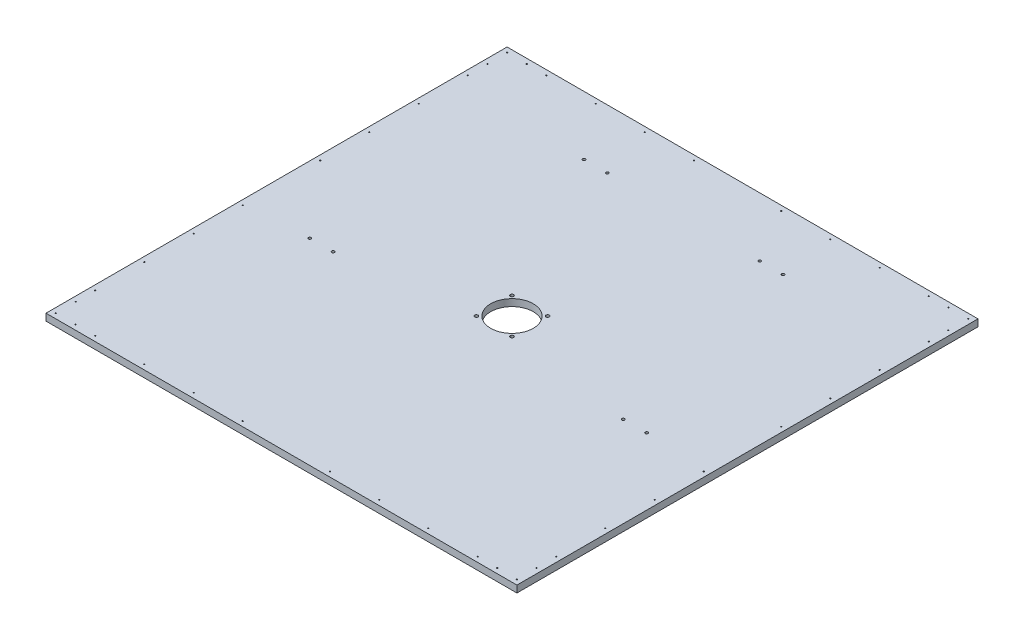
from build123d import *

# Parameters (mm, degrees)
SKETCH1_W               = 1216.025
SKETCH1_H               = 1190.625
BOSS_EXTRUDE1_DEPTH     = 17.8562
SKETCH3_R               = 55
CUT_EXTRUDE1_DEPTH      = 1
CUT_EXTRUDE1_DEPTH_BACK = 18.8562
SKETCH4_R               = 4.25
CUT_EXTRUDE2_DEPTH      = 1
CUT_EXTRUDE2_DEPTH_BACK = 18.8562
SKETCH5_R               = 1.3890625
CUT_EXTRUDE3_DEPTH      = 1
CUT_EXTRUDE3_DEPTH_BACK = 18.8562
SKETCH10_R              = 3.571875
CUT_EXTRUDE4_DEPTH      = 1
CUT_EXTRUDE4_DEPTH_BACK = 18.8562


with BuildPart() as part:
    # Sketch1 → Boss-Extrude1 (new body)
    with BuildSketch(Plane(origin=(0, 0, 0), x_dir=(1, 0, 0), z_dir=(0, 1, 0))):
        with Locations((608.0125, -595.3125)):
            Rectangle(SKETCH1_W, SKETCH1_H)
    extrude(amount=BOSS_EXTRUDE1_DEPTH)

    # Sketch3 → Cut-Extrude1 (cut, two sides)
    with BuildSketch(Plane(origin=(0, 17.8562, 0), x_dir=(1, 0, 0), z_dir=(0, 1, 0))) as cut_extrude1_sk:
        with Locations((608.0125, -595.376)):
            Circle(SKETCH3_R)
    extrude(amount=CUT_EXTRUDE1_DEPTH, mode=Mode.SUBTRACT)
    extrude(cut_extrude1_sk.sketch, amount=-CUT_EXTRUDE1_DEPTH_BACK, mode=Mode.SUBTRACT)

    # Sketch4 → Cut-Extrude2 (cut, two sides)
    with BuildSketch(Plane(origin=(0, 17.8562, 0), x_dir=(1, 0, 0), z_dir=(0, 1, 0))) as cut_extrude2_sk:
        with Locations((562.050559223, -549.414059223)):
            Circle(SKETCH4_R)
        with Locations((653.974440777, -549.414059223)):
            Circle(SKETCH4_R)
        with Locations((653.974440777, -641.337940777)):
            Circle(SKETCH4_R)
        with Locations((562.050559223, -641.337940777)):
            Circle(SKETCH4_R)
    extrude(amount=CUT_EXTRUDE2_DEPTH, mode=Mode.SUBTRACT)
    extrude(cut_extrude2_sk.sketch, amount=-CUT_EXTRUDE2_DEPTH_BACK, mode=Mode.SUBTRACT)

    # Sketch5 → Cut-Extrude3 (cut, two sides)
    with BuildSketch(Plane(origin=(0, 17.8562, 0), x_dir=(1, 0, 0), z_dir=(0, 1, 0))) as cut_extrude3_sk:
        with Locations((12.7, -12.7)):
            Circle(SKETCH5_R)
        with Locations((12.7, -63.5)):
            Circle(SKETCH5_R)
        with Locations((63.5, -12.7)):
            Circle(SKETCH5_R)
        with Locations((12.7, -114.3)):
            Circle(SKETCH5_R)
        with Locations((114.3, -12.7)):
            Circle(SKETCH5_R)
        with Locations((12.7, -241.3)):
            Circle(SKETCH5_R)
        with Locations((12.7, -368.3)):
            Circle(SKETCH5_R)
        with Locations((12.7, -495.3)):
            Circle(SKETCH5_R)
        with Locations((241.3, -12.7)):
            Circle(SKETCH5_R)
        with Locations((368.3, -12.7)):
            Circle(SKETCH5_R)
        with Locations((495.3, -12.7)):
            Circle(SKETCH5_R)
        with Locations((720.725, -12.7)):
            Circle(SKETCH5_R)
        with Locations((847.725, -12.7)):
            Circle(SKETCH5_R)
        with Locations((974.725, -12.7)):
            Circle(SKETCH5_R)
        with Locations((1203.325, -495.3)):
            Circle(SKETCH5_R)
        with Locations((1203.325, -368.3)):
            Circle(SKETCH5_R)
        with Locations((1203.325, -241.3)):
            Circle(SKETCH5_R)
        with Locations((1101.725, -12.7)):
            Circle(SKETCH5_R)
        with Locations((1203.325, -114.3)):
            Circle(SKETCH5_R)
        with Locations((1152.525, -12.7)):
            Circle(SKETCH5_R)
        with Locations((1203.325, -63.5)):
            Circle(SKETCH5_R)
        with Locations((1203.325, -12.7)):
            Circle(SKETCH5_R)
        with Locations((1203.325, -1177.925)):
            Circle(SKETCH5_R)
        with Locations((1203.325, -1127.125)):
            Circle(SKETCH5_R)
        with Locations((1152.525, -1177.925)):
            Circle(SKETCH5_R)
        with Locations((1203.325, -1076.325)):
            Circle(SKETCH5_R)
        with Locations((1101.725, -1177.925)):
            Circle(SKETCH5_R)
        with Locations((1203.325, -949.325)):
            Circle(SKETCH5_R)
        with Locations((1203.325, -822.325)):
            Circle(SKETCH5_R)
        with Locations((1203.325, -695.325)):
            Circle(SKETCH5_R)
        with Locations((974.725, -1177.925)):
            Circle(SKETCH5_R)
        with Locations((847.725, -1177.925)):
            Circle(SKETCH5_R)
        with Locations((720.725, -1177.925)):
            Circle(SKETCH5_R)
        with Locations((495.3, -1177.925)):
            Circle(SKETCH5_R)
        with Locations((368.3, -1177.925)):
            Circle(SKETCH5_R)
        with Locations((241.3, -1177.925)):
            Circle(SKETCH5_R)
        with Locations((12.7, -695.325)):
            Circle(SKETCH5_R)
        with Locations((12.7, -822.325)):
            Circle(SKETCH5_R)
        with Locations((12.7, -949.325)):
            Circle(SKETCH5_R)
        with Locations((114.3, -1177.925)):
            Circle(SKETCH5_R)
        with Locations((12.7, -1076.325)):
            Circle(SKETCH5_R)
        with Locations((63.5, -1177.925)):
            Circle(SKETCH5_R)
        with Locations((12.7, -1127.125)):
            Circle(SKETCH5_R)
        with Locations((12.7, -1177.925)):
            Circle(SKETCH5_R)
    extrude(amount=CUT_EXTRUDE3_DEPTH, mode=Mode.SUBTRACT)
    extrude(cut_extrude3_sk.sketch, amount=-CUT_EXTRUDE3_DEPTH_BACK, mode=Mode.SUBTRACT)

    # Sketch10 → Cut-Extrude4 (cut, two sides)
    with BuildSketch(Plane(origin=(0, 17.8562, 0), x_dir=(1, 0, 0), z_dir=(0, 1, 0))) as cut_extrude4_sk:
        with Locations((173.0375, -682.625)):
            Circle(SKETCH10_R)
        with Locations((233.3625, -682.625)):
            Circle(SKETCH10_R)
        with Locations((350.8375, -152.4)):
            Circle(SKETCH10_R)
        with Locations((411.1625, -152.4)):
            Circle(SKETCH10_R)
        with Locations((804.8625, -152.4)):
            Circle(SKETCH10_R)
        with Locations((865.1875, -152.4)):
            Circle(SKETCH10_R)
        with Locations((982.6625, -682.625)):
            Circle(SKETCH10_R)
        with Locations((1042.9875, -682.625)):
            Circle(SKETCH10_R)
    extrude(amount=CUT_EXTRUDE4_DEPTH, mode=Mode.SUBTRACT)
    extrude(cut_extrude4_sk.sketch, amount=-CUT_EXTRUDE4_DEPTH_BACK, mode=Mode.SUBTRACT)


solid = part.part
